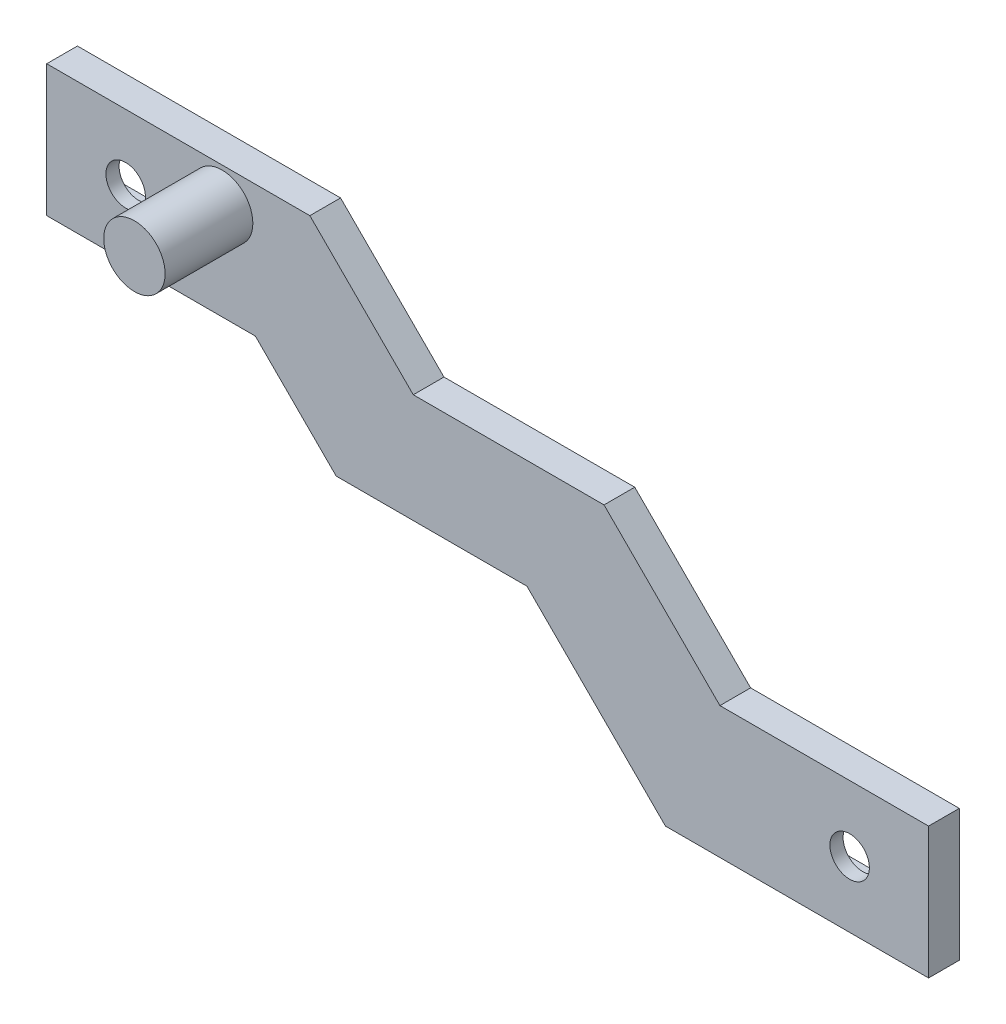
from build123d import *

# Parameters (mm, degrees)
SKETCH_1_W          = 100.539230484
SKETCH_1_H          = 40
SKETCH_1_W_2        = 17
SKETCH_1_H_2        = 7
EXTRUDE_1_DEPTH     = 2
SKETCH_2_W          = 100.539230484
SKETCH_2_H          = 40
SKETCH_2_R          = 2.25
EXTRUDE_2_DEPTH     = 1.5
SKETCH_3_W          = 184.808915215
SKETCH_3_H          = 94.825170589
CUT_EXTRUDE_1_DEPTH = 31.5
SKETCH_4_R          = 3.5
EXTRUDE_3_DEPTH     = 10


with BuildPart() as part:
    # Эскиз1 → Бобышка-Вытянуть1 (new body)
    with BuildSketch(Plane.XY):
        with Locations((62.5, 12.5)):
            Rectangle(SKETCH_1_W, SKETCH_1_H)
        with Locations((24.230384758, 25)):
            Rectangle(SKETCH_1_W_2, SKETCH_1_H_2, mode=Mode.SUBTRACT)
        with Locations((100.769615242, 0)):
            Rectangle(SKETCH_1_W_2, SKETCH_1_H_2, mode=Mode.SUBTRACT)
    extrude(amount=EXTRUDE_1_DEPTH)

    # Эскиз2 → Бобышка-Вытянуть2 (add)
    with BuildSketch(Plane.XY.offset(2)):
        with Locations((62.5, 12.5)):
            Rectangle(SKETCH_2_W, SKETCH_2_H)
        with Locations((21.230384758, 25)):
            Circle(SKETCH_2_R, mode=Mode.SUBTRACT)
        with Locations((103.769615242, 0)):
            Circle(SKETCH_2_R, mode=Mode.SUBTRACT)
    extrude(amount=EXTRUDE_2_DEPTH)

    # Эскиз3 → Вырез-Вытянуть1 (cut)
    with BuildSketch(Plane.XY.offset(3.5)):
        with Locations((81.231416835, 7.831688581)):
            Rectangle(SKETCH_3_W, SKETCH_3_H)
        Polygon((12.230384758, 32.5), (42.230384758, 32.5), (54.020384758, 20.71), (75.769615242, 20.71), (88.979615242, 7.5), (112.769615242, 7.5), (112.769615242, -7.5), (82.769615242, -7.5), (66.982818678, 8.286796564), (45.230384758, 8.286796564), (36.017181322, 17.5), (12.230384758, 17.5), align=None, mode=Mode.SUBTRACT)
    extrude(amount=-CUT_EXTRUDE_1_DEPTH, mode=Mode.SUBTRACT)

    # Эскиз4 → Бобышка-Вытянуть3 (add)
    with BuildSketch(Plane.XY.offset(3.5)):
        with Locations((32.230384758, 28.5)):
            Circle(SKETCH_4_R)
    extrude(amount=EXTRUDE_3_DEPTH)


solid = part.part
